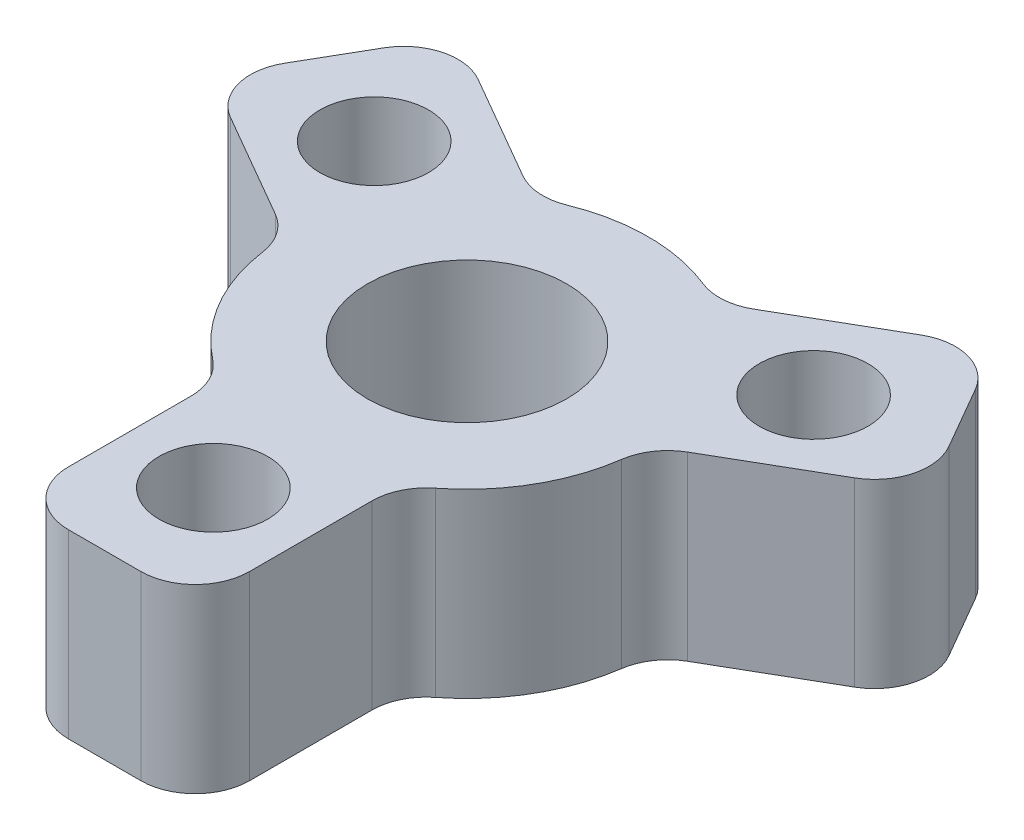
from build123d import *

# Parameters (mm, degrees)
SKETCH1_R                = 5
BOSS_EXTRUDE1_DEPTH      = 5
SKETCH2_W                = 5
SKETCH2_H                = 10
BOSS_EXTRUDE2_DEPTH      = 5
SKETCH3_R                = 1.5
CUT_EXTRUDE1_DEPTH       = 6
FILLET1_R                = 1.5
CIRPATTERN1_COUNT        = 3
FILLET1_OF_CIRPATTERN1_R = 1.5
SKETCH4_R                = 2.75
CUT_EXTRUDE2_DEPTH       = 6


with BuildPart() as part:
    # Sketch1 → Boss-Extrude1 (new body)
    with BuildSketch(Plane(origin=(0, 0, 0), x_dir=(1, 0, 0), z_dir=(0, 1, 0))):
        Circle(SKETCH1_R)
    extrude(amount=BOSS_EXTRUDE1_DEPTH)

    # Sketch2 → Boss-Extrude2 (add)
    with BuildSketch(Plane(origin=(0, 0, 0), x_dir=(1, 0, 0), z_dir=(0, 1, 0))):
        with Locations((0, -5)):
            Rectangle(SKETCH2_W, SKETCH2_H)
    boss_extrude2 = extrude(amount=BOSS_EXTRUDE2_DEPTH)

    # Sketch3 → Cut-Extrude1 (cut, through all)
    with BuildSketch(Plane(origin=(0, 5, 0), x_dir=(1, 0, 0), z_dir=(0, 1, 0))):
        with Locations((0, -7)):
            Circle(SKETCH3_R)
    cut_extrude1 = extrude(amount=-CUT_EXTRUDE1_DEPTH, mode=Mode.SUBTRACT)

    # Fillet1
    fillet1_edges = [part.edges().sort_by_distance(p)[0] for p in [
        (2.5, 2.5, 4.330127019),
        (2.5, 2.5, 10),
        (-2.5, 2.5, 4.330127019),
        (-2.5, 2.5, 10),
    ]]
    fillet(fillet1_edges, radius=FILLET1_R)

    # CirPattern1: Boss-Extrude2, Cut-Extrude1 ×3 about axis
    cirpattern1_axis = Axis((0, 0, 0), (0, 1, 0))
    for i in range(1, CIRPATTERN1_COUNT):
        add(boss_extrude2.rotate(cirpattern1_axis, i * 360 / CIRPATTERN1_COUNT))
        add(cut_extrude1.rotate(cirpattern1_axis, i * 360 / CIRPATTERN1_COUNT), mode=Mode.SUBTRACT)

    # Fillet1 of CirPattern1
    fillet1_of_cirpattern1_edges = [part.edges().sort_by_distance(p)[0] for p in [
        (2.5, 2.5, -4.330127019),
        (7.410254038, 2.5, -7.165063509),
        (5, 2.5, 0),
        (9.910254038, 2.5, -2.834936491),
        (-5, 2.5, 0),
        (-9.910254038, 2.5, -2.834936491),
        (-2.5, 2.5, -4.330127019),
        (-7.410254038, 2.5, -7.165063509),
    ]]
    fillet(fillet1_of_cirpattern1_edges, radius=FILLET1_OF_CIRPATTERN1_R)

    # Sketch4 → Cut-Extrude2 (cut, through all)
    with BuildSketch(Plane(origin=(0, 5, 0), x_dir=(1, 0, 0), z_dir=(0, 1, 0))):
        Circle(SKETCH4_R)
    extrude(amount=-CUT_EXTRUDE2_DEPTH, mode=Mode.SUBTRACT)


solid = part.part
